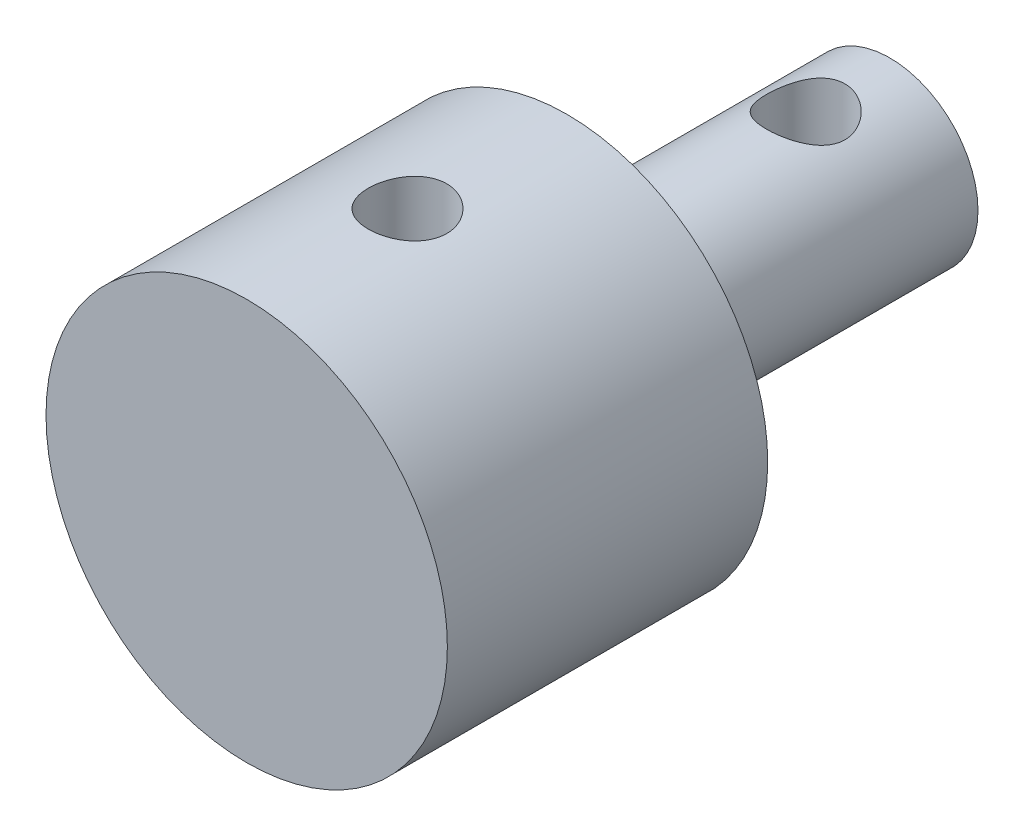
from build123d import *

# Parameters (mm, degrees)
SKETCH1_R               = 7.925
EXTRUDE1_DEPTH          = 25.4
SKETCH2_OUTSIDE_W       = 24.626
SKETCH2_OUTSIDE_H       = 24.626
SKETCH2_OUTSIDE_R       = 3.48
CUT_EXTRUDE1_DEPTH      = 12.75
SKETCH3_R               = 1.55
CUT_EXTRUDE2_DEPTH      = 8.925
CUT_EXTRUDE2_DEPTH_BACK = 8.925
SKETCH4_R               = 1.55
CUT_EXTRUDE3_DEPTH      = 8.925
CUT_EXTRUDE3_DEPTH_BACK = 8.925


with BuildPart() as part:
    # Sketch1 → Extrude1 (new body)
    with BuildSketch(Plane.XY):
        Circle(SKETCH1_R)
    extrude(amount=EXTRUDE1_DEPTH)

    # Sketch2 outside → Cut-Extrude1 (cut)
    with BuildSketch(Plane.XY):
        Rectangle(SKETCH2_OUTSIDE_W, SKETCH2_OUTSIDE_H)
        Circle(SKETCH2_OUTSIDE_R, mode=Mode.SUBTRACT)
    extrude(amount=CUT_EXTRUDE1_DEPTH, mode=Mode.SUBTRACT)

    # Sketch3 → Cut-Extrude2 (cut, two sides)
    with BuildSketch(Plane(origin=(0, 0, 0), x_dir=(1, 0, 0), z_dir=(0, 1, 0))) as cut_extrude2_sk:
        with Locations((0, -3.325)):
            Circle(SKETCH3_R)
    extrude(amount=CUT_EXTRUDE2_DEPTH, mode=Mode.SUBTRACT)
    extrude(cut_extrude2_sk.sketch, amount=-CUT_EXTRUDE2_DEPTH_BACK, mode=Mode.SUBTRACT)

    # Sketch4 → Cut-Extrude3 (cut, two sides)
    with BuildSketch(Plane(origin=(0, 0, 0), x_dir=(1, 0, 0), z_dir=(0, 1, 0))) as cut_extrude3_sk:
        with Locations((0, -19.05)):
            Circle(SKETCH4_R)
    extrude(amount=CUT_EXTRUDE3_DEPTH, mode=Mode.SUBTRACT)
    extrude(cut_extrude3_sk.sketch, amount=-CUT_EXTRUDE3_DEPTH_BACK, mode=Mode.SUBTRACT)


solid = part.part
